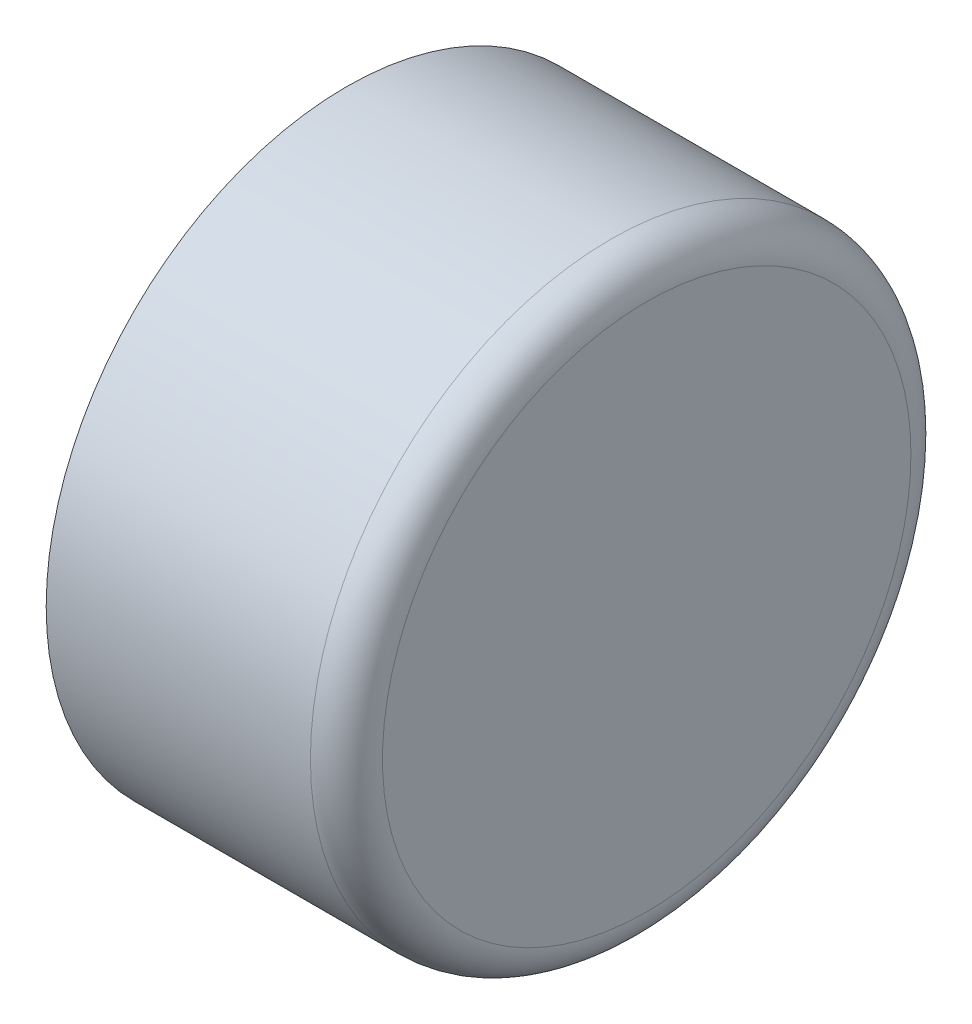
from build123d import *


with BuildPart() as part:
    # Sketch2 → Revolve1 (revolve)
    with BuildSketch(Plane(origin=(0, 0, 0), x_dir=(1, 0, 0), z_dir=(0, 1, 0))):
        with BuildLine():
            Line((0, 0), (0, 8.001))
            ThreePointArc((0, 8.001), (-0.446369265, 9.078630735), (-1.524, 9.525))
            Line((-1.524, 9.525), (-7.9248, 9.525))
            Line((-7.9248, 9.525), (-7.9248, 11.1125))
            Line((-7.9248, 11.1125), (-9.525, 11.1125))
            Line((-9.525, 11.1125), (-9.525, 12.7))
            Line((-9.525, 12.7), (1.651, 12.7))
            ThreePointArc((1.651, 12.7), (2.728630735, 12.253630735), (3.175, 11.176))
            Line((3.175, 11.176), (3.175, 0))
            Line((3.175, 0), (0, 0))
        make_face()
    revolve(axis=Axis((3.175, 0, 0), (-1, 0, 0)))


solid = part.part
